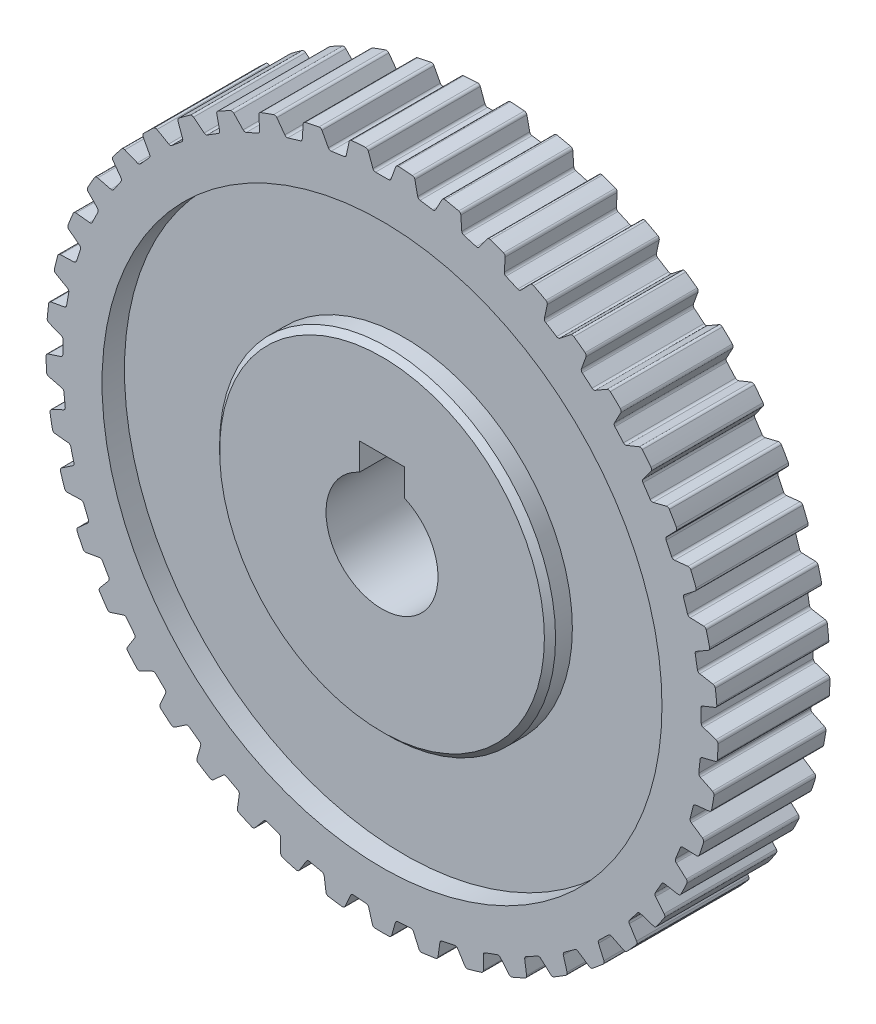
from build123d import *

# Parameters (mm, degrees)
SKETCH1_R               = 30
BOSS_EXTRUDE1_DEPTH     = 10
CUT_EXTRUDE1_DEPTH      = 11
CIRPATTERN1_COUNT       = 45
SKETCH3_R               = 25
SKETCH3_R_2             = 15
CUT_EXTRUDE_THIN1_DEPTH = 2
CHAMFER1_SIZE           = 0.5
CHAMFER2_SIZE           = 0.5
FILLET1_R               = 0.25


with BuildPart() as part:
    # Sketch1 → Boss-Extrude1 (new body)
    with BuildSketch(Plane.XY):
        Circle(SKETCH1_R)
        with BuildLine():
            ThreePointArc((-2, 4.582575695), (0, -5), (2, 4.582575695))
            Line((2, 4.582575695), (2, 7))
            Line((2, 7), (-2, 7))
            Line((-2, 7), (-2, 4.582575695))
        make_face(mode=Mode.SUBTRACT)
    extrude(amount=BOSS_EXTRUDE1_DEPTH)

    # Sketch2 → Cut-Extrude1 (cut, through all)
    with BuildSketch(Plane.XY.offset(10)):
        Polygon((-50.976281067, 166.495573095), (-1.285919783, 29.972427501), (-0.75, 28.5), (0.75, 28.5), (1.285919783, 29.972427501), (50.976281067, 166.495573095), (50.976281067, 457.065367035), (-50.976281067, 457.065367035), align=None)
    cut_extrude1 = extrude(amount=-CUT_EXTRUDE1_DEPTH, mode=Mode.SUBTRACT)

    # CirPattern1: Cut-Extrude1 ×45 about axis
    cirpattern1_axis = Axis((0, 0, 0), (0, 0, 1))
    for i in range(1, CIRPATTERN1_COUNT):
        add(cut_extrude1.rotate(cirpattern1_axis, i * 360 / CIRPATTERN1_COUNT), mode=Mode.SUBTRACT)

    # Sketch3 → Cut-Extrude-Thin1 (cut)
    with BuildSketch(Plane.XY.offset(10)):
        Circle(SKETCH3_R)
        Circle(SKETCH3_R_2, mode=Mode.SUBTRACT)
    cut_extrude_thin1 = extrude(amount=-CUT_EXTRUDE_THIN1_DEPTH, mode=Mode.SUBTRACT)

    # Chamfer1
    chamfer1_edges = [part.edges().sort_by_distance(p)[0] for p in [
        (-15, 0, 10),
    ]]
    chamfer(chamfer1_edges, length=CHAMFER1_SIZE)

    # Mirror2: Cut-Extrude-Thin1 across plane
    add(cut_extrude_thin1.mirror(Plane.XY.offset(5)), mode=Mode.SUBTRACT)

    # Chamfer2
    chamfer2_edges = [part.edges().sort_by_distance(p)[0] for p in [
        (-15, 0, 0),
    ]]
    chamfer(chamfer2_edges, length=CHAMFER2_SIZE)

    # Fillet1
    fillet1_edges = [part.edges().sort_by_distance(p)[0] for p in [
        (0.75, 28.5, 5),
        (-0.75, 28.5, 5),
        (-1.285919783, 29.972427501, 5),
        (1.285919783, 29.972427501, 5),
        (28.265477671, -3.724952625, 5),
        (28.422270365, -2.233169782, 5),
        (29.942650626, -1.854096408, 5),
        (29.673820188, -4.411847167, 5),
        (27.471986777, -7.622495819, 5),
        (27.834869621, -6.16705223, 5),
        (29.393210462, -6.003264007, 5),
        (28.771026159, -8.498708946, 5),
        (26.14378491, -11.371675803, 5),
        (26.7056948, -9.980900021, 5),
        (28.27166489, -10.035584902, 5),
        (27.308236832, -12.420153023, 5),
        (24.306724008, -14.899519053, 5),
        (25.056724008, -13.600480947, 5),
        (26.59984352, -13.872574552, 5),
        (25.313923738, -16.099852949, 5),
        (21.996560371, -18.137360112, 5),
        (22.920052584, -16.955343982, 5),
        (24.410286453, -17.439550318, 5),
        (22.826903912, -19.466187551, 5),
        (19.258258708, -21.022178087, 5),
        (20.337268408, -19.980190532, 5),
        (21.745610926, -20.667085074, 5),
        (19.895584367, -22.453634955, 5),
        (16.145116945, -23.497823279, 5),
        (17.358642436, -22.6161454, 5),
        (18.657681818, -23.492358527, 5),
        (16.577019903, -25.004047895, 5),
        (12.717728845, -25.516110069, 5),
        (14.042150234, -24.811902724, 5),
        (15.206602156, -25.860379944, 5),
        (12.935802603, -27.067785484, 5),
        (9.042804619, -27.0377548, 5),
        (10.45234355, -26.524724585, 5),
        (11.45954328, -27.725058482, 5),
        (9.042804619, -28.604679418, 5),
        (5.191872488, -28.033140389, 5),
        (6.659093889, -27.721272853, 5),
        (7.48943743, -29.050100292, 5),
        (4.97379873, -29.584815805, 5),
        (1.239886464, -28.482892788, 5),
        (2.736232539, -28.378258077, 5),
        (3.373558199, -29.809714945, 5),
        (0.807983505, -29.989117404, 5),
        (-2.736232539, -28.378258077, 5),
        (-1.239886464, -28.482892788, 5),
        (-0.807983505, -29.989117404, 5),
        (-3.373558199, -29.809714945, 5),
        (-6.659093889, -27.721272853, 5),
        (-5.191872488, -28.033140389, 5),
        (-4.97379873, -29.584815805, 5),
        (-7.48943743, -29.050100292, 5),
        (-10.45234355, -26.524724585, 5),
        (-9.042804619, -27.0377548, 5),
        (-9.042804619, -28.604679418, 5),
        (-11.45954328, -27.725058482, 5),
        (-14.042150234, -24.811902724, 5),
        (-12.717728845, -25.516110069, 5),
        (-12.935802603, -27.067785484, 5),
        (-15.206602156, -25.860379944, 5),
        (-17.358642436, -22.6161454, 5),
        (-16.145116945, -23.497823279, 5),
        (-16.577019903, -25.004047895, 5),
        (-18.657681818, -23.492358527, 5),
        (-20.337268408, -19.980190532, 5),
        (-19.258258708, -21.022178087, 5),
        (-19.895584367, -22.453634955, 5),
        (-21.745610926, -20.667085074, 5),
        (-22.920052584, -16.955343982, 5),
        (-21.996560371, -18.137360112, 5),
        (-22.826903912, -19.466187551, 5),
        (-24.410286453, -17.439550318, 5),
        (-25.056724008, -13.600480947, 5),
        (-24.306724008, -14.899519053, 5),
        (-25.313923738, -16.099852949, 5),
        (-26.59984352, -13.872574552, 5),
        (-26.7056948, -9.980900021, 5),
        (-26.14378491, -11.371675803, 5),
        (-27.308236832, -12.420153023, 5),
        (-28.27166489, -10.035584902, 5),
        (-27.834869621, -6.16705223, 5),
        (-27.471986777, -7.622495819, 5),
        (-28.771026159, -8.498708946, 5),
        (-29.393210462, -6.003264007, 5),
        (-28.422270365, -2.233169782, 5),
        (-28.265477671, -3.724952625, 5),
        (-29.673820188, -4.411847167, 5),
        (-29.942650626, -1.854096408, 5),
        (-28.456463948, 1.744178776, 5),
        (-28.508813193, 0.245092536, 5),
        (-29.999047061, -0.2391138, 5),
        (-29.909291155, 2.33115907, 5),
        (-27.936784828, 5.687578878, 5),
        (-28.197257094, 4.210367249, 5),
        (-29.740376607, 3.938273644, 5),
        (-29.293781353, 6.471041187, 5),
        (-26.873347969, 9.520276727, 5),
        (-27.33687346, 8.093691952, 5),
        (-28.90284355, 8.039007072, 5),
        (-28.108101418, 10.484971849, 5),
        (-25.286851959, 13.167673218, 5),
        (-25.94440868, 11.819482149, 5),
        (-27.502749521, 11.983270371, 5),
        (-26.375329261, 14.29482446, 5),
        (-23.20817614, 16.558775928, 5),
        (-24.046965495, 15.31521957, 5),
        (-25.567345756, 15.694292943, 5),
        (-24.129191322, 17.826444573, 5),
        (-20.677779571, 19.6275809, 5),
        (-21.681475481, 18.512863662, 5),
        (-23.134302688, 19.099843956, 5),
        (-21.413406121, 21.01109322, 5),
        (-17.744913544, 22.314357336, 5),
        (-18.893980208, 21.350175922, 5),
        (-20.250976734, 22.133638231, 5),
        (-18.280833326, 23.786784837, 5),
        (-14.466662959, 24.566810189, 5),
        (-15.738735103, 23.771931292, 5),
        (-16.973488552, 24.736626415, 5),
        (-14.792444905, 26.099493745, 5),
        (-10.906835234, 26.341098025, 5),
        (-12.277153421, 25.730993061, 5),
        (-13.365630723, 26.858144303, 5),
        (-11.01613837, 27.904205694, 5),
        (-7.134718369, 27.602686351, 5),
        (-8.576610913, 27.189230317, 5),
        (-9.497626095, 28.456898963, 5),
        (-7.025415233, 29.16579402, 5),
        (28.508813193, 0.245092536, 5),
        (28.456463948, 1.744178776, 5),
        (29.909291155, 2.33115907, 5),
        (29.999047061, -0.2391138, 5),
        (28.197257094, 4.210367249, 5),
        (27.936784828, 5.687578878, 5),
        (29.293781353, 6.471041187, 5),
        (29.740376607, 3.938273644, 5),
        (27.33687346, 8.093691952, 5),
        (26.873347969, 9.520276727, 5),
        (28.108101418, 10.484971849, 5),
        (28.90284355, 8.039007072, 5),
        (25.94440868, 11.819482149, 5),
        (25.286851959, 13.167673218, 5),
        (26.375329261, 14.29482446, 5),
        (27.502749521, 11.983270371, 5),
        (24.046965495, 15.31521957, 5),
        (23.20817614, 16.558775928, 5),
        (24.129191322, 17.826444573, 5),
        (25.567345756, 15.694292943, 5),
        (21.681475481, 18.512863662, 5),
        (20.677779571, 19.6275809, 5),
        (21.413406121, 21.01109322, 5),
        (23.134302688, 19.099843956, 5),
        (18.893980208, 21.350175922, 5),
        (17.744913544, 22.314357336, 5),
        (18.280833326, 23.786784837, 5),
        (20.250976734, 22.133638231, 5),
        (15.738735103, 23.771931292, 5),
        (14.466662959, 24.566810189, 5),
        (14.792444905, 26.099493745, 5),
        (16.973488552, 24.736626415, 5),
        (12.277153421, 25.730993061, 5),
        (10.906835234, 26.341098025, 5),
        (11.01613837, 27.904205694, 5),
        (13.365630723, 26.858144303, 5),
        (8.576610913, 27.189230317, 5),
        (7.134718369, 27.602686351, 5),
        (7.025415233, 29.16579402, 5),
        (9.497626095, 28.456898963, 5),
        (4.709134429, 28.118260133, 5),
        (3.223732326, 28.327019785, 5),
        (2.897950379, 29.859703341, 5),
        (5.444760978, 29.501772453, 5),
        (-3.223732326, 28.327019785, 5),
        (-4.709134429, 28.118260133, 5),
        (-5.444760978, 29.501772453, 5),
        (-2.897950379, 29.859703341, 5),
    ]]
    fillet(fillet1_edges, radius=FILLET1_R)


solid = part.part
